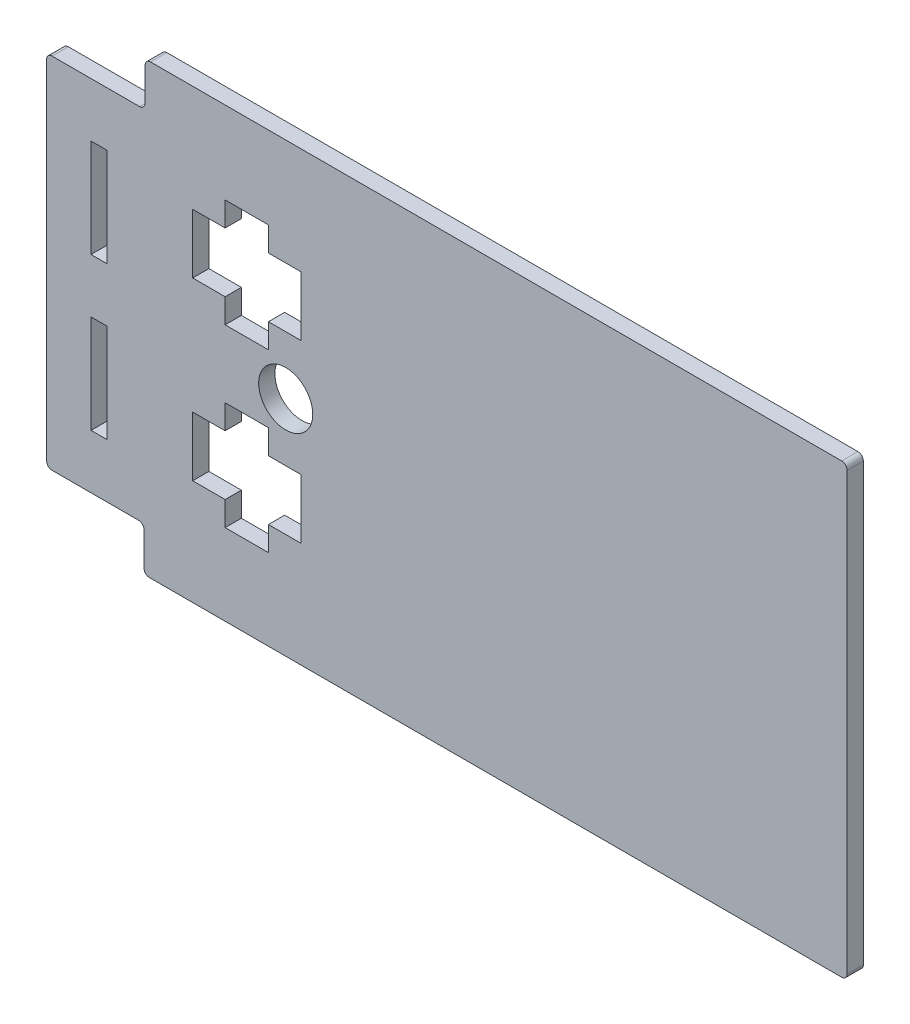
from build123d import *

# Parameters (mm, degrees)
MODEL_R                 = 5
MODEL_W                 = 3
MODEL_H                 = 18.163611367
MODEL_H_2               = 18.163611368
SALIENTE_EXTRUIR1_DEPTH = 3


with BuildPart() as part:
    # Model → Saliente-Extruir1 (new body)
    with BuildSketch(Plane.XY):
        with BuildLine():
            Line((110.507104, 49.029117707), (-17.27548715, 49.029117707))
            ThreePointArc((-17.27548715, 49.029117707), (-17.98412567, 48.739950134), (-18.280736421, 48.034394679))
            Line((-18.280736421, 48.034394679), (-18.313224497, 41.861702909))
            ThreePointArc((-18.313224497, 41.861702909), (-18.609835248, 41.156147454), (-19.318473769, 40.866979881))
            Line((-19.318473769, 40.866979881), (-35.492896, 40.856340442))
            ThreePointArc((-35.492896, 40.856340442), (-36.200002781, 40.563447224), (-36.492896, 39.856340442))
            Line((-36.492896, 39.856340442), (-36.492896, -24.470882293))
            ThreePointArc((-36.492896, -24.470882293), (-36.200002781, -25.177989074), (-35.492896, -25.470882293))
            Line((-35.492896, -25.470882293), (-19.492896, -25.470882293))
            ThreePointArc((-19.492896, -25.470882293), (-18.785789219, -25.763775512), (-18.492896, -26.470882293))
            Line((-18.492896, -26.470882293), (-18.492896, -32.643659558))
            ThreePointArc((-18.492896, -32.643659558), (-18.200002781, -33.350766339), (-17.492896, -33.643659558))
            Line((-17.492896, -33.643659558), (26.507104, -33.643659558))
            Line((26.507104, -33.643659558), (32.507104, -33.643659558))
            Line((32.507104, -33.643659558), (65.191293724, -33.643659558))
            Line((65.191293724, -33.643659558), (110.507104, -33.643659558))
            ThreePointArc((110.507104, -33.643659558), (111.214210781, -33.350766339), (111.507104, -32.643659558))
            Line((111.507104, -32.643659558), (111.507104, 48.029117707))
            ThreePointArc((111.507104, 48.029117707), (111.214210781, 48.736224488), (110.507104, 49.029117707))
        make_face()
        with Locations((7.707104, 7.592729075)):
            Circle(MODEL_R, mode=Mode.SUBTRACT)
        Polygon((10.507104, 18.329117707), (4.507104, 18.329117707), (4.507104, 13.829117707), (-3.492896, 13.829117707), (-3.492896, 18.329117707), (-9.492896, 18.329117707), (-9.492896, 29.329117707), (-3.492896, 29.329117707), (-3.492896, 33.829117707), (4.507104, 33.829117707), (4.507104, 29.329117707), (10.507104, 29.329117707), align=None, mode=Mode.SUBTRACT)
        Polygon((10.507104, -3.143659558), (4.507104, -3.143659558), (4.507104, 1.356340442), (-3.492896, 1.356340442), (-3.492896, -3.143659558), (-9.492896, -3.143659558), (-9.492896, -14.143659558), (-3.492896, -14.143659558), (-3.492896, -18.643659558), (4.507104, -18.643659558), (4.507104, -14.143659558), (10.507104, -14.143659558), align=None, mode=Mode.SUBTRACT)
        with Locations((-26.792896, 21.774534758)):
            Rectangle(MODEL_W, MODEL_H, mode=Mode.SUBTRACT)
        with Locations((-26.792896, -6.389076609)):
            Rectangle(MODEL_W, MODEL_H_2, mode=Mode.SUBTRACT)
    extrude(amount=SALIENTE_EXTRUIR1_DEPTH)


solid = part.part
